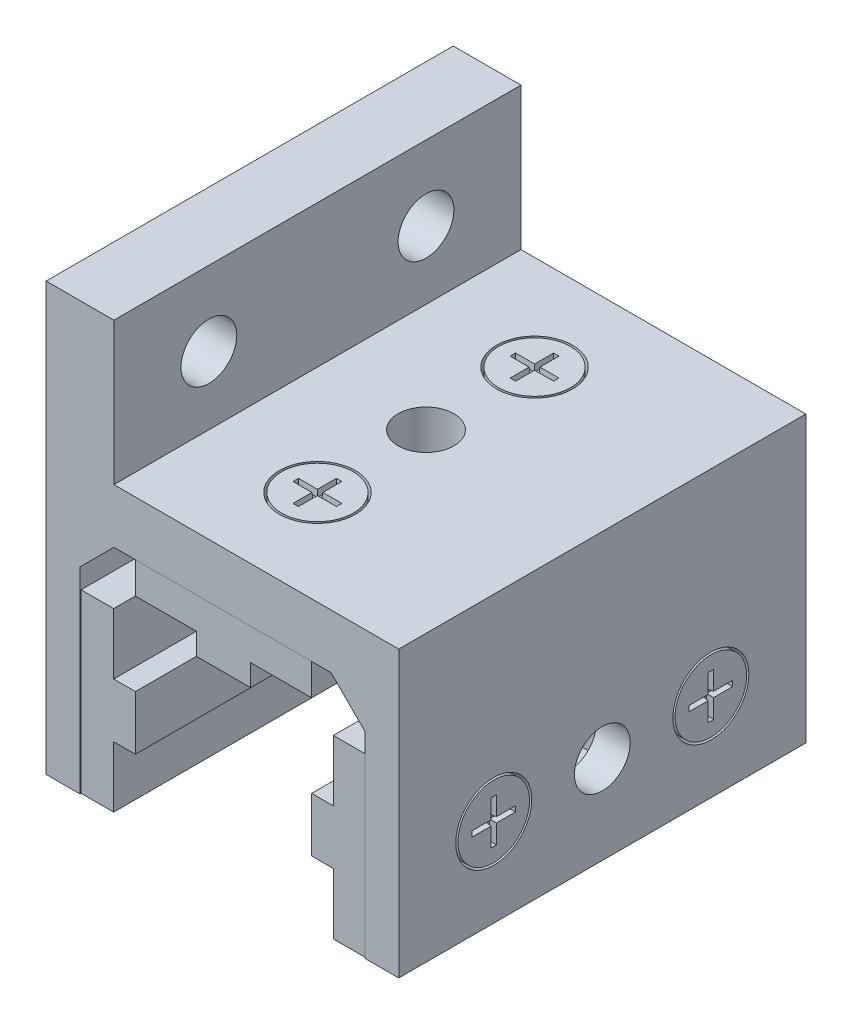
from build123d import *

# Parameters (mm, degrees)
BOSS_EXTRUDE1_DEPTH       = 23.8125
BOSS_EXTRUDE2_DEPTH       = 23.6855
BOSS_EXTRUDE2_2_DEPTH     = 23.6855
SKETCH11_W                = 6.35
SKETCH11_H                = 6.35
CUT_EXTRUDE5_DEPTH        = 11.3124
SKETCH12_W                = 6.35
SKETCH12_H                = 6.35
CUT_EXTRUDE6_DEPTH        = 13.7
SKETCH3_R                 = 4.445
SKETCH3_R_2               = 4.191
CUT_EXTRUDE1_DEPTH        = 3.175
CUT_EXTRUDE2_DEPTH        = 0.762
CUT_EXTRUDE2_TAPER        = 5
SKETCH13_R                = 4.445
SKETCH13_R_2              = 4.191
CUT_EXTRUDE_THIN1_DEPTH   = 1.9812
CUT_EXTRUDE7_DEPTH        = 0.762
CUT_EXTRUDE7_TAPER        = 5
MIRROR3_COPY_1_SKETCH_R   = 4.445
MIRROR3_COPY_1_SKETCH_R_2 = 4.191
MIRROR3_COPY_1_DEPTH      = 1.9812
MIRROR3_COPY_2_DEPTH      = 0.762
MIRROR3_COPY_2_TAPER      = 5
SKETCH9_R                 = 3.2639
CUT_EXTRUDE4_DEPTH        = 34.3248
SKETCH15_R                = 3.2639
CUT_EXTRUDE8_DEPTH        = 21.6248001
CUT_EXTRUDE8_DEPTH_BACK   = 21.6248001
SIDE_START                = -23.8125
SKETCH6_W                 = 7.9248
SKETCH6_H                 = 23.0124
SIDE_FLANGE_DEPTH         = 47.625
SKETCH7_R                 = 3.2639
SIDE_FLANGE_HOLE_DEPTH    = 21.6248001
SKETCH16_W                = 1.9812
SKETCH16_H                = 7.9248
TOP_FLANGE_DEPTH          = 23.8125
TOP_FLANGE_DEPTH_BACK     = 23.8125


with BuildPart() as part:
    # Sketch1 → Boss-Extrude1 (new body, symmetric)
    with BuildSketch(Plane.XY):
        Polygon((-16.6624, 0), (-16.6624, 23.0124), (-12.7, 26.9748), (12.7, 26.9748), (16.6624, 23.0124), (16.6624, 0), (20.6248, 0), (20.6248, 33.3248), (-20.6248, 33.3248), (-20.6248, 0), align=None)
    extrude(amount=BOSS_EXTRUDE1_DEPTH, both=True)

    # Sketch3 → Cut-Extrude1 (cut)
    with BuildSketch(Plane(origin=(0, 33.3248, 0), x_dir=(1, 0, 0), z_dir=(0, 1, 0))):
        with Locations((0, -12.7)):
            Circle(SKETCH3_R)
        with Locations((0, -12.7)):
            Circle(SKETCH3_R_2, mode=Mode.SUBTRACT)
    cut_extrude1 = extrude(amount=-CUT_EXTRUDE1_DEPTH, mode=Mode.SUBTRACT)

    # Sketch5 → Cut-Extrude2 (cut)
    with BuildSketch(Plane(origin=(0, 33.3248, 0), x_dir=(1, 0, 0), z_dir=(0, 1, 0))):
        Polygon((0.3175, -12.3825), (0.3175, -10.16), (-0.3175, -10.16), (-0.3175, -12.3825), (-2.54, -12.3825), (-2.54, -13.0175), (-0.3175, -13.0175), (-0.3175, -15.24), (0.3175, -15.24), (0.3175, -13.0175), (2.54, -13.0175), (2.54, -12.3825), align=None)
    cut_extrude2 = extrude(amount=-CUT_EXTRUDE2_DEPTH, taper=CUT_EXTRUDE2_TAPER, mode=Mode.SUBTRACT)

    # Sketch13 → Cut-Extrude-Thin1 (cut)
    with BuildSketch(Plane(origin=(20.6248, 0, 0), x_dir=(0, 0, -1), z_dir=(1, 0, 0))):
        with Locations((-12.7, 10.3124)):
            Circle(SKETCH13_R)
        with Locations((-12.7, 10.3124)):
            Circle(SKETCH13_R_2, mode=Mode.SUBTRACT)
    cut_extrude_thin1 = extrude(amount=-CUT_EXTRUDE_THIN1_DEPTH, mode=Mode.SUBTRACT)

    # Sketch14 → Cut-Extrude7 (cut)
    with BuildSketch(Plane(origin=(20.6248, 0, 0), x_dir=(0, 0, -1), z_dir=(1, 0, 0))):
        Polygon((-13.0175, 9.9949), (-13.0175, 7.7724), (-12.3825, 7.7724), (-12.3825, 9.9949), (-10.16, 9.9949), (-10.16, 10.6299), (-12.3825, 10.6299), (-12.3825, 12.8524), (-13.0175, 12.8524), (-13.0175, 10.6299), (-15.24, 10.6299), (-15.24, 9.9949), align=None)
    cut_extrude7 = extrude(amount=-CUT_EXTRUDE7_DEPTH, taper=CUT_EXTRUDE7_TAPER, mode=Mode.SUBTRACT)

    # Mirror4: Cut-Extrude-Thin1, Cut-Extrude7 across plane
    add(cut_extrude_thin1.mirror(Plane(origin=(0, 0, 0), x_dir=(0, 0, 1), z_dir=(1, 0, 0))), mode=Mode.SUBTRACT)
    add(cut_extrude7.mirror(Plane(origin=(0, 0, 0), x_dir=(0, 0, 1), z_dir=(1, 0, 0))), mode=Mode.SUBTRACT)

    # Mirror3: Cut-Extrude-Thin1, Cut-Extrude7, Cut-Extrude1, Cut-Extrude2 across plane
    add(cut_extrude_thin1.mirror(Plane.XY), mode=Mode.SUBTRACT)
    add(cut_extrude7.mirror(Plane.XY), mode=Mode.SUBTRACT)
    add(cut_extrude1.mirror(Plane.XY), mode=Mode.SUBTRACT)
    add(cut_extrude2.mirror(Plane.XY), mode=Mode.SUBTRACT)

    # Mirror3 copy 1 sketch → Mirror3 copy 1 (cut)
    with BuildSketch(Plane.ZY.offset(20.6248)):
        with Locations((-12.7, 10.3124)):
            Circle(MIRROR3_COPY_1_SKETCH_R)
        with Locations((-12.7, 10.3124)):
            Circle(MIRROR3_COPY_1_SKETCH_R_2, mode=Mode.SUBTRACT)
    extrude(amount=-MIRROR3_COPY_1_DEPTH, mode=Mode.SUBTRACT)

    # Mirror3 copy 2 sketch → Mirror3 copy 2 (cut)
    with BuildSketch(Plane.ZY.offset(20.6248)):
        Polygon((-13.0175, 9.9949), (-13.0175, 7.7724), (-12.3825, 7.7724), (-12.3825, 9.9949), (-10.16, 9.9949), (-10.16, 10.6299), (-12.3825, 10.6299), (-12.3825, 12.8524), (-13.0175, 12.8524), (-13.0175, 10.6299), (-15.24, 10.6299), (-15.24, 9.9949), align=None)
    extrude(amount=-MIRROR3_COPY_2_DEPTH, taper=MIRROR3_COPY_2_TAPER, mode=Mode.SUBTRACT)

    # Sketch9 → Cut-Extrude4 (cut, through all)
    with BuildSketch(Plane(origin=(0, 33.3248, 0), x_dir=(1, 0, 0), z_dir=(0, 1, 0))):
        Circle(SKETCH9_R)
    extrude(amount=-CUT_EXTRUDE4_DEPTH, mode=Mode.SUBTRACT)

    # Sketch15 → Cut-Extrude8 (cut, two sides)
    with BuildSketch(Plane(origin=(0, 0, 0), x_dir=(0, 0, -1), z_dir=(1, 0, 0))) as cut_extrude8_sk:
        with Locations((0, 10.3124)):
            Circle(SKETCH15_R)
    extrude(amount=CUT_EXTRUDE8_DEPTH, mode=Mode.SUBTRACT)
    extrude(cut_extrude8_sk.sketch, amount=-CUT_EXTRUDE8_DEPTH_BACK, mode=Mode.SUBTRACT)

    # Sketch6 → Side Flange (add)
    with BuildSketch(Plane.XY.offset(SIDE_START)):
        with Locations((-16.6624, 38.481)):
            Rectangle(SKETCH6_W, SKETCH6_H)
    extrude(amount=SIDE_FLANGE_DEPTH)

    # Sketch7 → Side Flange Hole (cut, through all)
    with BuildSketch(Plane(origin=(0, 0, 0), x_dir=(0, 0, -1), z_dir=(1, 0, 0))):
        with Locations((-12.7, 41.275)):
            Circle(SKETCH7_R)
        with Locations((12.7, 41.275)):
            Circle(SKETCH7_R)
    extrude(amount=-SIDE_FLANGE_HOLE_DEPTH, mode=Mode.SUBTRACT)

    # Sketch16 → Top Flange (add, two sides)
    with BuildSketch(Plane.XY) as top_flange_sk:
        with Locations((-19.6342, 29.3624)):
            Rectangle(SKETCH16_W, SKETCH16_H)
        with Locations((19.6342, 29.3624)):
            Rectangle(SKETCH16_W, SKETCH16_H)
    extrude(amount=TOP_FLANGE_DEPTH)
    extrude(top_flange_sk.sketch, amount=-TOP_FLANGE_DEPTH_BACK)


with BuildPart() as body_2:
    # Sketch2 → Boss-Extrude2 (new body, symmetric)
    with BuildSketch(Plane.XY):
        Polygon((-12.8524, 13.4874), (-12.8524, 20.6248), (-16.6624, 20.6248), (-16.6624, 0), (-12.8524, 0), (-12.8524, 7.1374), (-10.3124, 7.1374), (-10.3124, 13.4874), align=None)
    extrude(amount=BOSS_EXTRUDE2_DEPTH, both=True)

    # Sketch11 → Cut-Extrude5 (cut, through all)
    with BuildSketch(Plane(origin=(-10.3124, 0, 0), x_dir=(0, 0, -1), z_dir=(1, 0, 0))):
        with Locations((0, 10.3124)):
            Rectangle(SKETCH11_W, SKETCH11_H)
    extrude(amount=-CUT_EXTRUDE5_DEPTH, mode=Mode.SUBTRACT)


with BuildPart() as body_3:
    # Sketch2 → Boss-Extrude2 2 (new body, symmetric)
    with BuildSketch(Plane.XY):
        Polygon((-10.3124, 26.9748), (10.3124, 26.9748), (10.3124, 23.1648), (3.175, 23.1648), (3.175, 20.6248), (-3.175, 20.6248), (-3.175, 23.1648), (-10.3124, 23.1648), align=None)
    extrude(amount=BOSS_EXTRUDE2_2_DEPTH, both=True)

    # Sketch12 → Cut-Extrude6 (cut, through all)
    with BuildSketch(Plane.XZ.offset(-20.6248)):
        Rectangle(SKETCH12_W, SKETCH12_H)
    extrude(amount=-CUT_EXTRUDE6_DEPTH, mode=Mode.SUBTRACT)


with BuildPart() as body_4:
    # Mirror1: mirrored copy
    add(body_2.part.mirror(Plane(origin=(0, 0, 0), x_dir=(0, 0, 1), z_dir=(1, 0, 0))))


solid = Compound([part.part, body_2.part, body_3.part, body_4.part])
